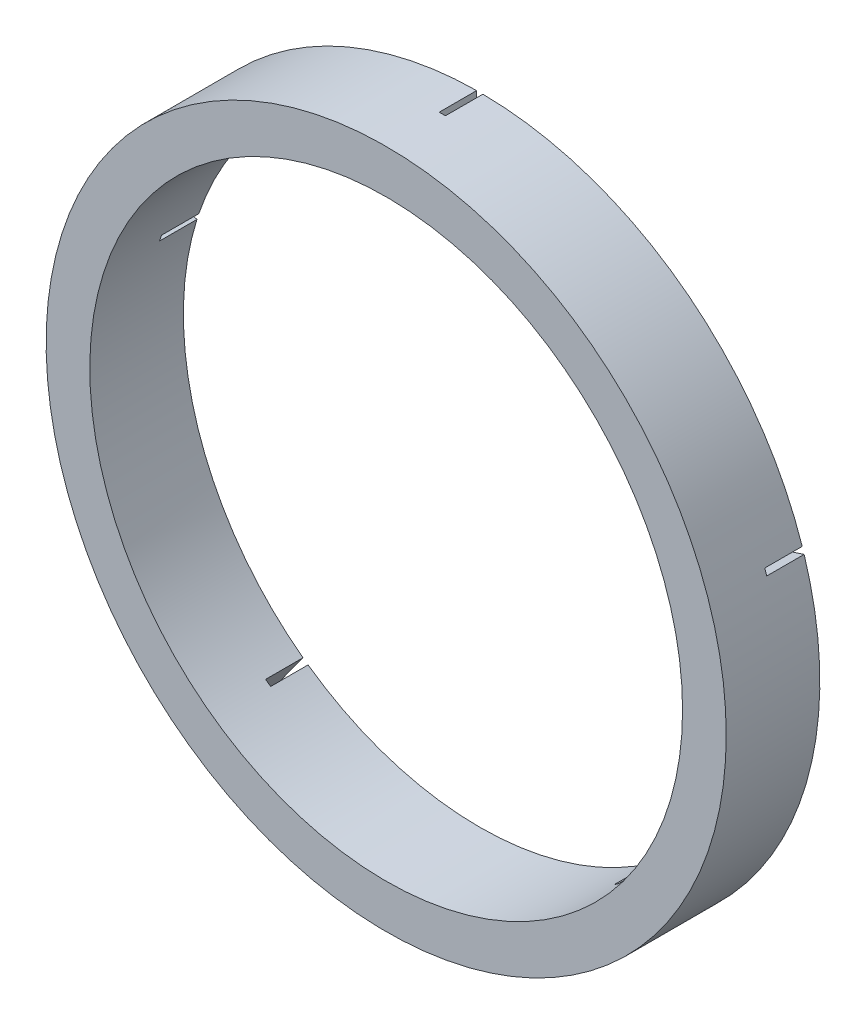
from build123d import *

# Parameters (mm, degrees)
ESQUISSE1_R             = 54.5
ESQUISSE1_R_2           = 47.5
BOSS_EXTRU_1_DEPTH      = 15
ESQUISSE2_W             = 1
ESQUISSE2_H             = 9.520304005
ENL_V_MAT_EXTRU_1_DEPTH = 6


with BuildPart() as part:
    # Esquisse1 → Boss.-Extru.1 (new body)
    with BuildSketch(Plane.XY):
        Circle(ESQUISSE1_R)
        Circle(ESQUISSE1_R_2, mode=Mode.SUBTRACT)
    extrude(amount=BOSS_EXTRU_1_DEPTH)

    # Esquisse2 → Enlèv. mat.-Extru.1 (cut)
    with BuildSketch(Plane(origin=(0, 0, 0), x_dir=(-1, 0, 0), z_dir=(0, 0, -1))):
        with BuildLine():
            Line((32.437456587, -43.795677985), (28.322761135, -38.132285556))
            ThreePointArc((28.322761135, -38.132285556), (27.919799484, -38.428307233), (27.513744141, -38.720070808))
            Line((27.513744141, -38.720070808), (31.628439593, -44.383463237))
            ThreePointArc((31.628439593, -44.383463237), (32.03429625, -44.091426193), (32.437456587, -43.795677985))
        make_face()
        with BuildLine():
            ThreePointArc((-45.327190172, 14.20196575), (-45.175184524, 14.678307233), (-45.018173177, 15.153022266))
            Line((-45.018173177, 15.153022266), (-51.675890273, 17.316245682))
            ThreePointArc((-51.675890273, 17.316245682), (-51.832580138, 16.841426193), (-51.984907267, 16.365189166))
            Line((-51.984907267, 16.365189166), (-45.327190172, 14.20196575))
        make_face()
        Polygon((-26.511777811, -37.340982466), (-32.107672102, -45.043070198), (-32.916689096, -44.455284946), (-27.320794805, -36.753197214), align=None)
        Polygon((43.3969576, 14.626257393), (52.451304761, 17.568193122), (52.760321755, 16.617136606), (43.705974594, 13.675200877), align=None)
        with Locations((0, 50.552873414)):
            Rectangle(ESQUISSE2_W, ESQUISSE2_H)
    extrude(amount=-ENL_V_MAT_EXTRU_1_DEPTH, mode=Mode.SUBTRACT)


solid = part.part
